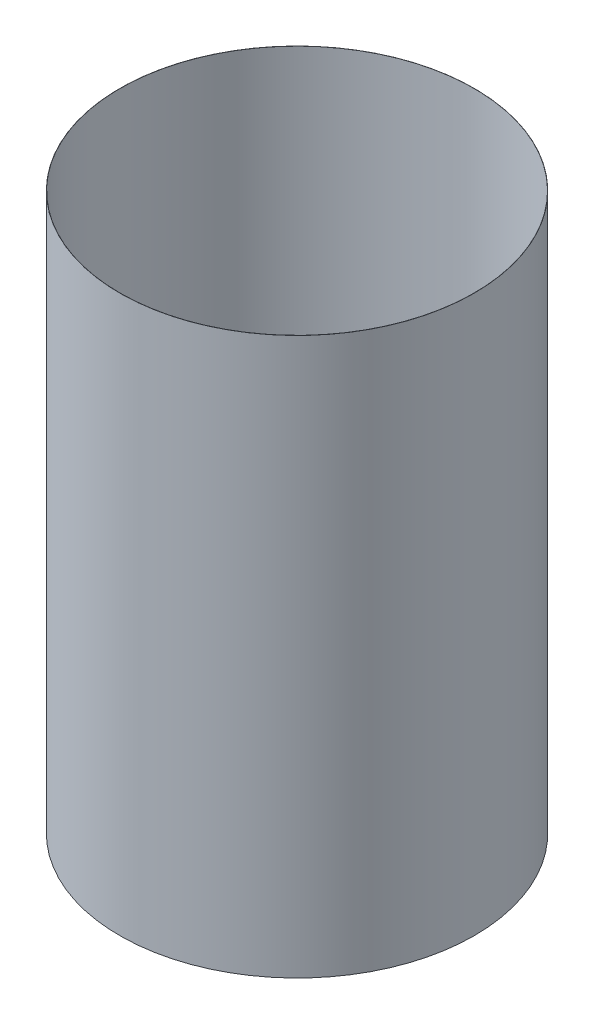
from build123d import *

# Parameters (mm, degrees)
ESQUISSE1_R        = 111.508460165
ESQUISSE1_R_2      = 111.408460165
EXTRU_MINCE1_DEPTH = 350


with BuildPart() as part:
    # Esquisse1 → Extru.-Mince1 (new body)
    with BuildSketch(Plane(origin=(0, 0, 0), x_dir=(1, 0, 0), z_dir=(0, 1, 0))):
        Circle(ESQUISSE1_R)
        Circle(ESQUISSE1_R_2, mode=Mode.SUBTRACT)
    extrude(amount=EXTRU_MINCE1_DEPTH)


solid = part.part
